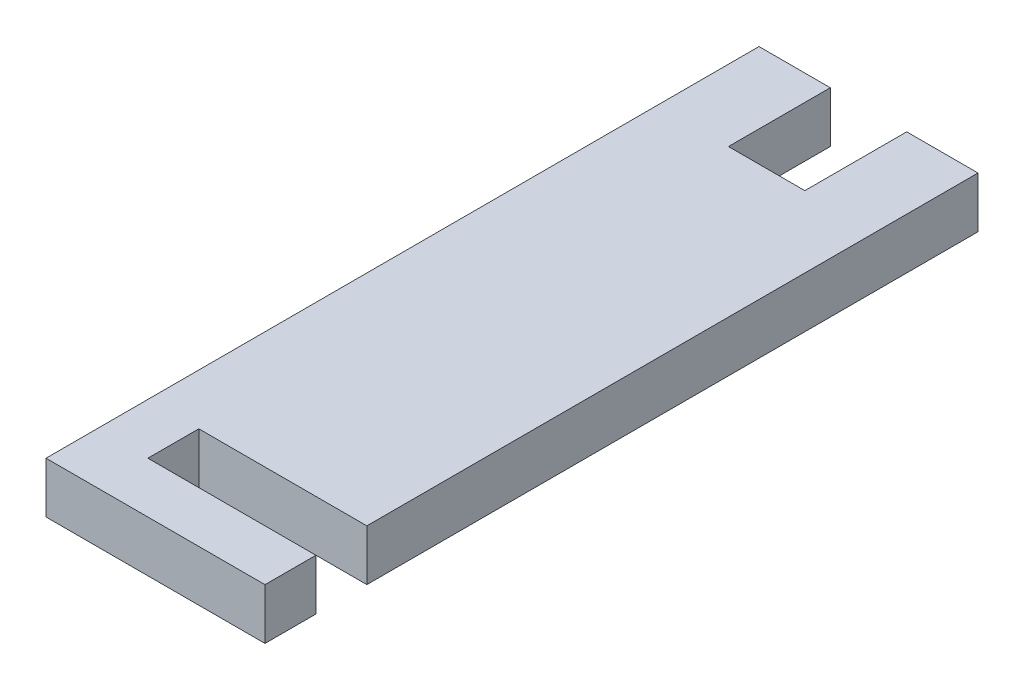
from build123d import *

# Parameters (mm, degrees)
BOSS_EXTRUDE1_DEPTH = 5


with BuildPart() as part:
    # Sketch1 → Boss-Extrude1 (new body)
    with BuildSketch(Plane(origin=(0, 0, 0), x_dir=(1, 0, 0), z_dir=(0, 1, 0))):
        Polygon((-10.75, 35), (-3.75, 35), (-3.75, 25), (3.75, 25), (3.75, 35), (10.75, 35), (10.75, -25), (-5.75, -25), (-5.75, -30), (10.75, -30), (10.75, -35), (-10.75, -35), align=None)
    extrude(amount=BOSS_EXTRUDE1_DEPTH)


solid = part.part
